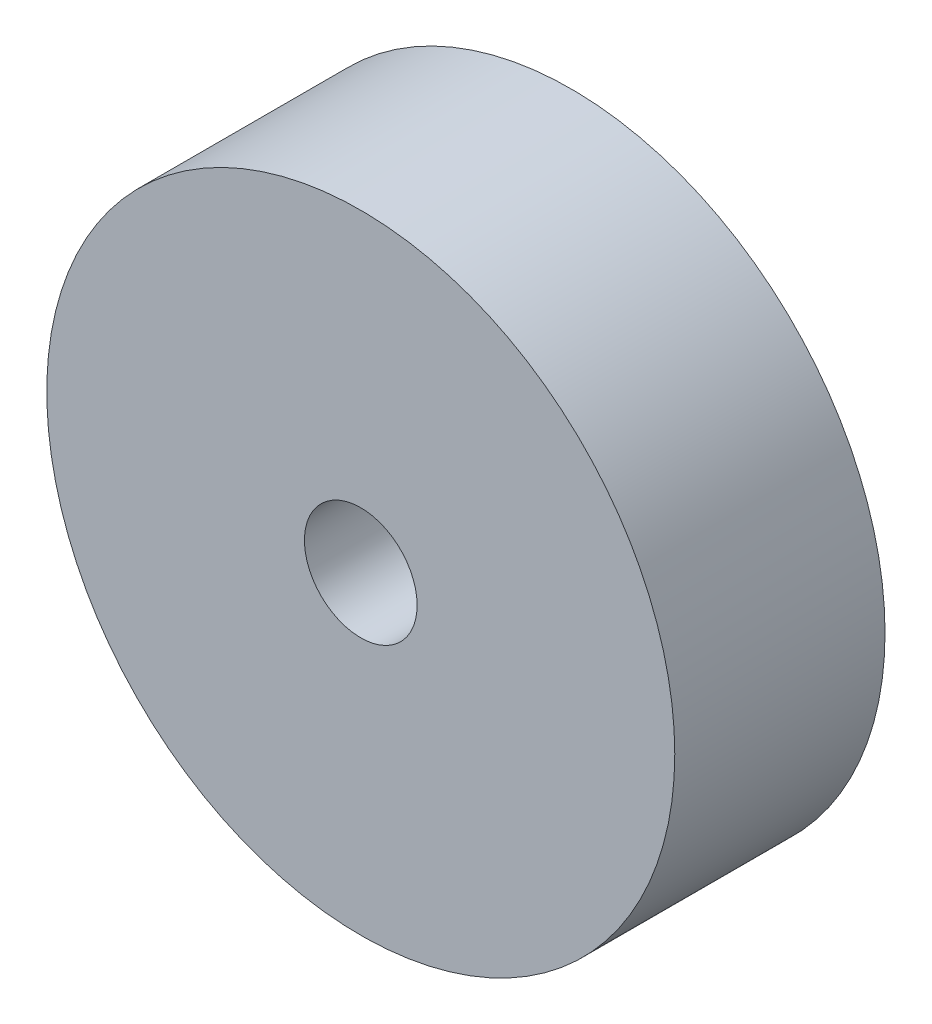
from build123d import *

# Parameters (mm, degrees)
SKETCH1_R              = 14.224
BOSS_EXTRUDE1_DEPTH    = 9.525
F_10_CLEARANCE_HOLE1_D = 5.1054


with BuildPart() as part:
    # Sketch1 → Boss-Extrude1 (new body)
    with BuildSketch(Plane.XY):
        Circle(SKETCH1_R)
    extrude(amount=BOSS_EXTRUDE1_DEPTH)

    # #10 Clearance Hole1 (through all)
    with Locations(Plane.XY.offset(9.525)):
        with Locations((0, 0)):
            Hole(F_10_CLEARANCE_HOLE1_D / 2)


solid = part.part
